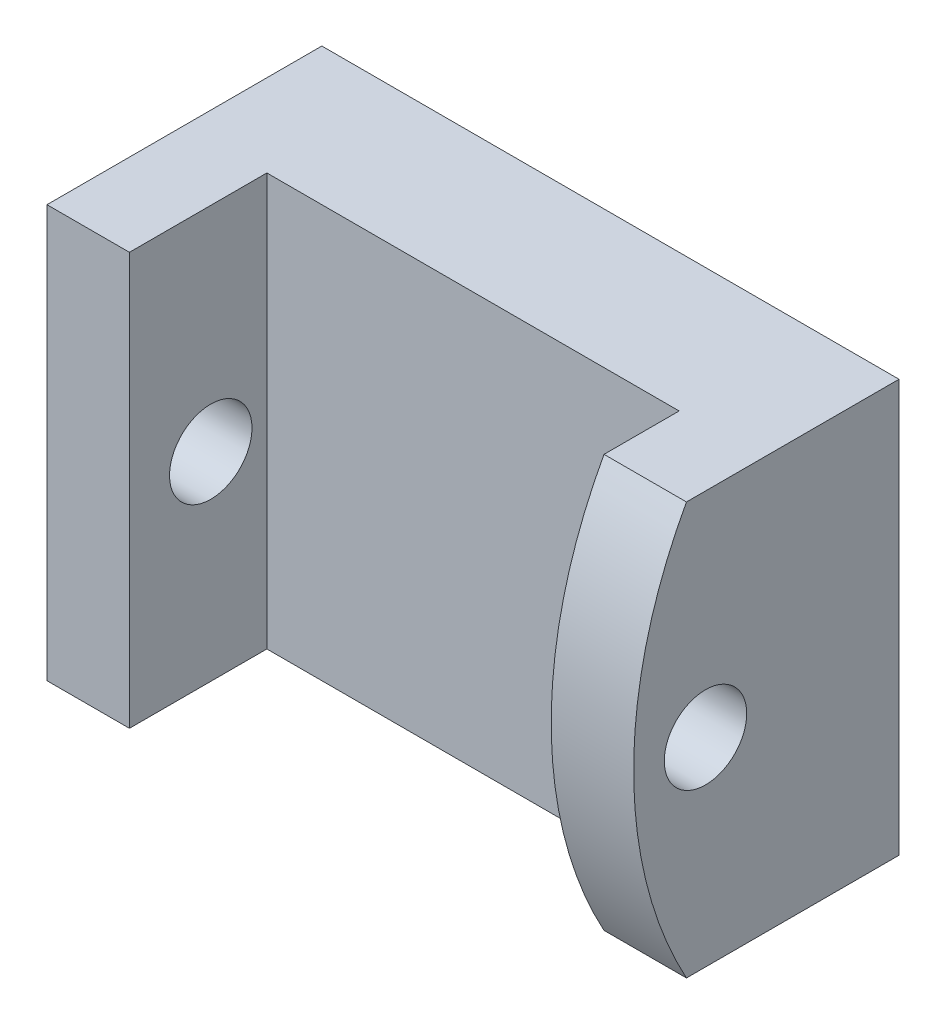
from build123d import *

# Parameters (mm, degrees)
SKETCH1_W               = 21
SKETCH1_H               = 15
BOSS_EXTRUDE1_DEPTH     = 5
SKETCH2_W               = 3
SKETCH2_H               = 15
BOSS_EXTRUDE2_DEPTH     = 5
CUT_EXTRUDE1_DEPTH      = 18
SKETCH4_R               = 1.5
CUT_EXTRUDE2_DEPTH      = 19
CUT_EXTRUDE2_DEPTH_BACK = 4


with BuildPart() as part:
    # Sketch1 → Boss-Extrude1 (new body)
    with BuildSketch(Plane.XY):
        with Locations((-10.5, -7.5)):
            Rectangle(SKETCH1_W, SKETCH1_H)
    extrude(amount=BOSS_EXTRUDE1_DEPTH)

    # Sketch2 → Boss-Extrude2 (add)
    with BuildSketch(Plane.XY.offset(5)):
        with Locations((-1.5, -7.5)):
            Rectangle(SKETCH2_W, SKETCH2_H)
        with Locations((-19.5, -7.5)):
            Rectangle(SKETCH2_W, SKETCH2_H)
    extrude(amount=BOSS_EXTRUDE2_DEPTH)

    # Sketch3 → Cut-Extrude1 (cut)
    with BuildSketch(Plane(origin=(0, 0, 0), x_dir=(0, 0, -1), z_dir=(1, 0, 0))):
        with BuildLine():
            Line((-7.733661886, 0), (-10, 0))
            Line((-10, 0), (-10, -15))
            Line((-10, -15), (-7.733661886, -15))
            ThreePointArc((-7.733661886, -15), (-9.654849758, -7.5), (-7.733661886, 0))
        make_face()
    extrude(amount=-CUT_EXTRUDE1_DEPTH, mode=Mode.SUBTRACT)

    # Sketch4 → Cut-Extrude2 (cut, two sides)
    with BuildSketch(Plane(origin=(-18, 0, 0), x_dir=(0, 0, -1), z_dir=(1, 0, 0))) as cut_extrude2_sk:
        with Locations((-7.041389116, -7.762480296)):
            Circle(SKETCH4_R)
    extrude(amount=CUT_EXTRUDE2_DEPTH, mode=Mode.SUBTRACT)
    extrude(cut_extrude2_sk.sketch, amount=-CUT_EXTRUDE2_DEPTH_BACK, mode=Mode.SUBTRACT)


solid = part.part
